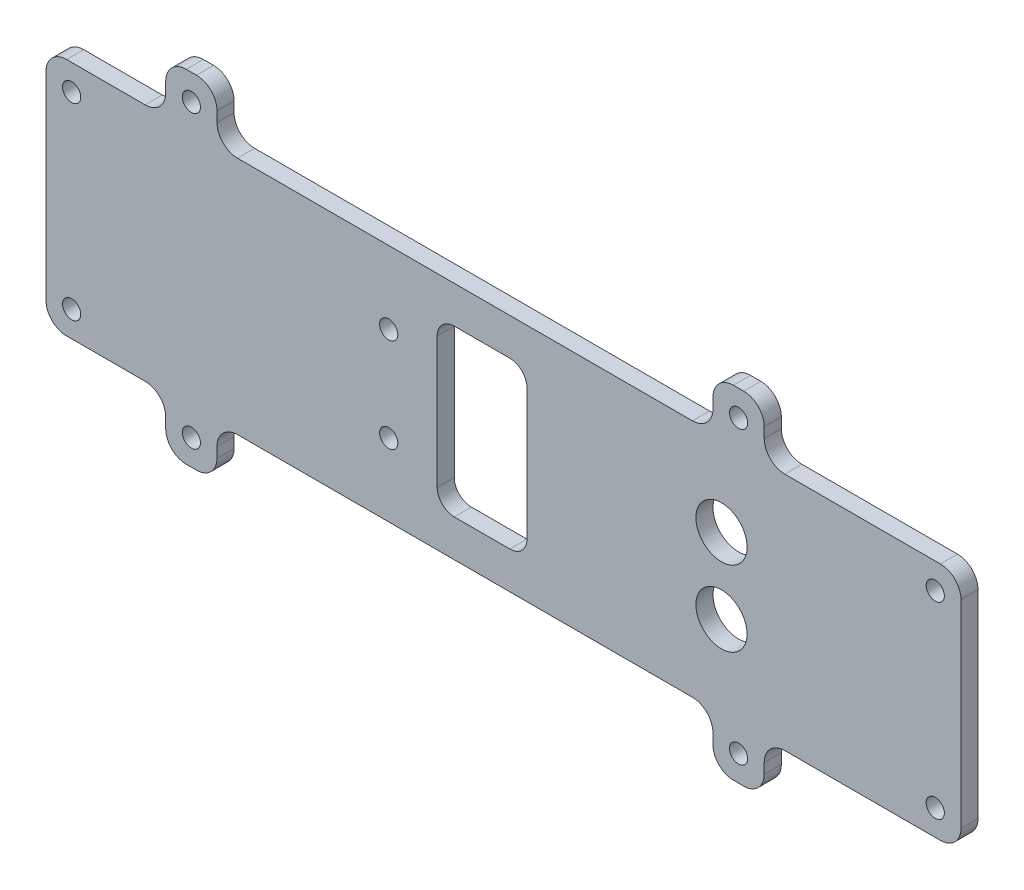
from build123d import *

# Parameters (mm, degrees)
SKETCH1_W               = 254
SKETCH1_H               = 88.9
SKETCH1_R               = 9.5
SKETCH1_W_2             = 27
SKETCH1_H_2             = 55
BOSS_EXTRUDE1_DEPTH     = 6.35
SKETCH4_W               = 19.05
SKETCH4_H               = 19.05
BOSS_EXTRUDE2_DEPTH     = 6.35
SKETCH7_W               = 34.925
SKETCH7_H               = 88.9
SKETCH7_W_2             = 50.8
BOSS_EXTRUDE3_DEPTH     = 6.35
F_1_4_CLEARANCE_HOLE1_D = 6.7564
FILLET1_R               = 3.175
FILLET2_R               = 7.62
CUT_EXTRUDE1_DEPTH      = 7.35


with BuildPart() as part:
    # Sketch1 → Boss-Extrude1 (new body)
    with BuildSketch(Plane(origin=(0, 0, 0), x_dir=(-1, 0, 0), z_dir=(0, 0, -1))):
        Rectangle(SKETCH1_W, SKETCH1_H)
        with Locations((-88.9000016, 14)):
            Circle(SKETCH1_R, mode=Mode.SUBTRACT)
        with Locations((-88.9000016, -14)):
            Circle(SKETCH1_R, mode=Mode.SUBTRACT)
        Rectangle(SKETCH1_W_2, SKETCH1_H_2, mode=Mode.SUBTRACT)
    extrude(amount=-BOSS_EXTRUDE1_DEPTH)

    # Sketch4 → Boss-Extrude2 (add)
    with BuildSketch(Plane.XY.offset(6.35)):
        with Locations((-107.95, 53.975)):
            Rectangle(SKETCH4_W, SKETCH4_H)
        with Locations((-107.95, -53.975)):
            Rectangle(SKETCH4_W, SKETCH4_H)
        with Locations((95.25, -53.975)):
            Rectangle(SKETCH4_W, SKETCH4_H)
        with Locations((95.25, 53.975)):
            Rectangle(SKETCH4_W, SKETCH4_H)
    extrude(amount=-BOSS_EXTRUDE2_DEPTH)

    # Sketch7 → Boss-Extrude3 (add)
    with BuildSketch(Plane.XY.offset(6.35)):
        with Locations((-144.4625, 0)):
            Rectangle(SKETCH7_W, SKETCH7_H)
        with Locations((152.4, 0)):
            Rectangle(SKETCH7_W_2, SKETCH7_H)
    extrude(amount=-BOSS_EXTRUDE3_DEPTH)

    # 1_4 Clearance Hole1 (through all)
    with Locations(Plane.XY.offset(6.35)):
        with Locations((-107.95, 53.975), (95.25, 53.975), (95.25, -53.975), (-107.95, -53.975), (168.275, -34.925), (168.275, 34.925), (-152.4, 34.925), (-152.4, -34.925), (-34.675, 17.4625), (-34.675, -17.4625)):
            Hole(F_1_4_CLEARANCE_HOLE1_D / 2)

    # Fillet1
    fillet1_edges = [part.edges().sort_by_distance(p)[0] for p in [
        (13.5, 27.5, 3.175),
        (-13.5, 27.5, 3.175),
        (-13.5, -27.5, 3.175),
        (13.5, -27.5, 3.175),
    ]]
    fillet(fillet1_edges, radius=FILLET1_R)

    # Fillet2
    fillet2_edges = [part.edges().sort_by_distance(p)[0] for p in [
        (-98.425, 44.45, 3.175),
        (-98.425, 63.5, 3.175),
        (-117.475, 63.5, 3.175),
        (-117.475, 44.45, 3.175),
        (-98.425, -63.5, 3.175),
        (-98.425, -44.45, 3.175),
        (-117.475, -44.45, 3.175),
        (-117.475, -63.5, 3.175),
        (85.725, -63.5, 3.175),
        (104.775, -63.5, 3.175),
        (104.775, -44.45, 3.175),
        (85.725, -44.45, 3.175),
        (85.725, 63.5, 3.175),
        (85.725, 44.45, 3.175),
        (104.775, 44.45, 3.175),
        (104.775, 63.5, 3.175),
        (-161.925, 44.45, 3.175),
        (-161.925, -44.45, 3.175),
        (177.8, -44.45, 3.175),
        (177.8, 44.45, 3.175),
    ]]
    fillet(fillet2_edges, radius=FILLET2_R)

    # Sketch8 → Cut-Extrude1 (cut, through all)
    with BuildSketch(Plane(origin=(0, 0, 0), x_dir=(-1, 0, 0), z_dir=(0, 0, -1))):
        with BuildLine():
            Line((10.325, 30.675), (-10.325, 30.675))
            ThreePointArc((-10.325, 30.675), (-14.815128061, 28.815128061), (-16.675, 24.325))
            Line((-16.675, 24.325), (-16.675, -24.325))
            ThreePointArc((-16.675, -24.325), (-14.815128061, -28.815128061), (-10.325, -30.675))
            Line((-10.325, -30.675), (10.325, -30.675))
            ThreePointArc((10.325, -30.675), (14.815128061, -28.815128061), (16.675, -24.325))
            Line((16.675, -24.325), (16.675, 24.325))
            ThreePointArc((16.675, 24.325), (14.815128061, 28.815128061), (10.325, 30.675))
        make_face()
        with BuildLine():
            Line((10.325, 27.5), (-10.325, 27.5))
            ThreePointArc((-10.325, 27.5), (-12.57006403, 26.57006403), (-13.5, 24.325))
            Line((-13.5, 24.325), (-13.5, -24.325))
            ThreePointArc((-13.5, -24.325), (-12.57006403, -26.57006403), (-10.325, -27.5))
            Line((-10.325, -27.5), (10.325, -27.5))
            ThreePointArc((10.325, -27.5), (12.57006403, -26.57006403), (13.5, -24.325))
            Line((13.5, -24.325), (13.5, 24.325))
            ThreePointArc((13.5, 24.325), (12.57006403, 26.57006403), (10.325, 27.5))
        make_face(mode=Mode.SUBTRACT)
    extrude(amount=-CUT_EXTRUDE1_DEPTH, mode=Mode.SUBTRACT)


solid = part.part
